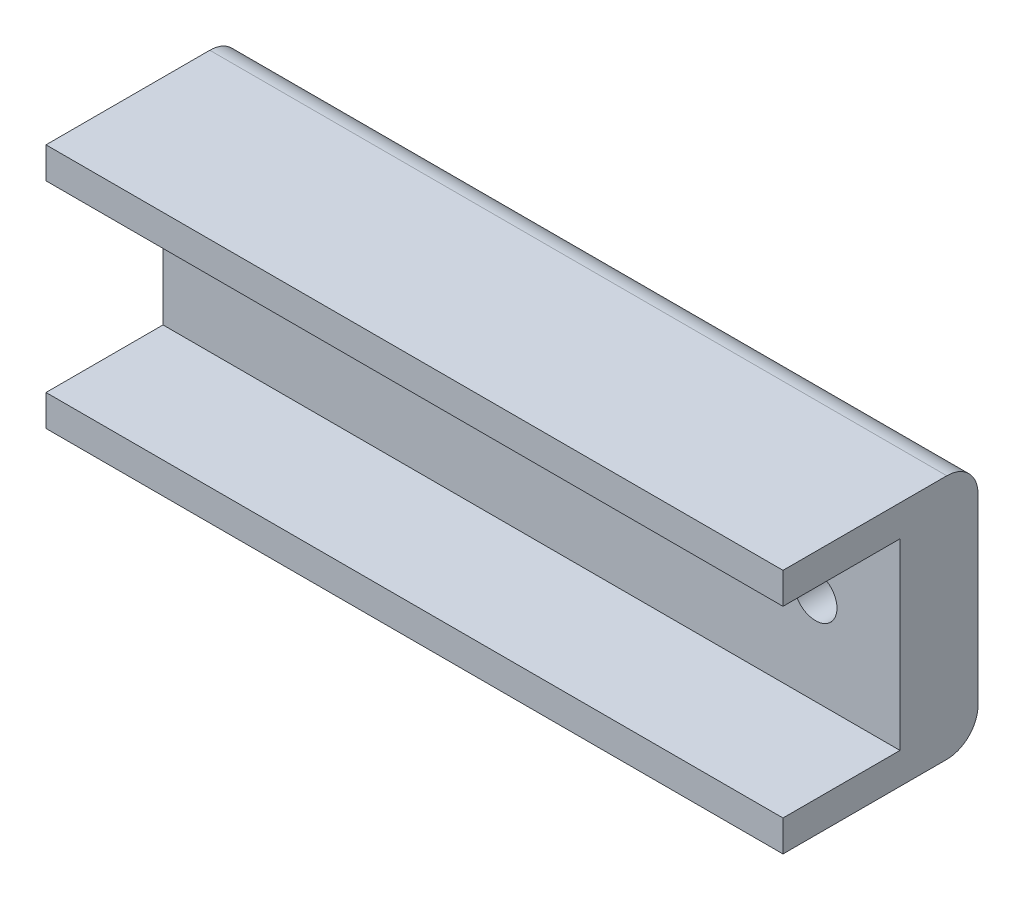
from build123d import *

# Parameters (mm, degrees)
SKETCH1_W           = 60
SKETCH1_H           = 20
SKETCH1_R           = 1.75
BOSS_EXTRUDE1_DEPTH = 6.35
SKETCH2_W           = 60
SKETCH2_H           = 2.54
BOSS_EXTRUDE2_DEPTH = 9.525
FILLET1_R           = 2.54


with BuildPart() as part:
    # Sketch1 → Boss-Extrude1 (new body)
    with BuildSketch(Plane.XY):
        Rectangle(SKETCH1_W, SKETCH1_H)
        with Locations((-23.12, 0)):
            Circle(SKETCH1_R, mode=Mode.SUBTRACT)
        with Locations((23.12, 0)):
            Circle(SKETCH1_R, mode=Mode.SUBTRACT)
    extrude(amount=BOSS_EXTRUDE1_DEPTH)

    # Sketch2 → Boss-Extrude2 (add)
    with BuildSketch(Plane.XY.offset(6.35)):
        with Locations((0, 8.73)):
            Rectangle(SKETCH2_W, SKETCH2_H)
        with Locations((0, -8.73)):
            Rectangle(SKETCH2_W, SKETCH2_H)
    extrude(amount=BOSS_EXTRUDE2_DEPTH)

    # Fillet1
    fillet1_edges = [part.edges().sort_by_distance(p)[0] for p in [
        (0, 10, 0),
        (0, -10, 0),
    ]]
    fillet(fillet1_edges, radius=FILLET1_R)


solid = part.part
